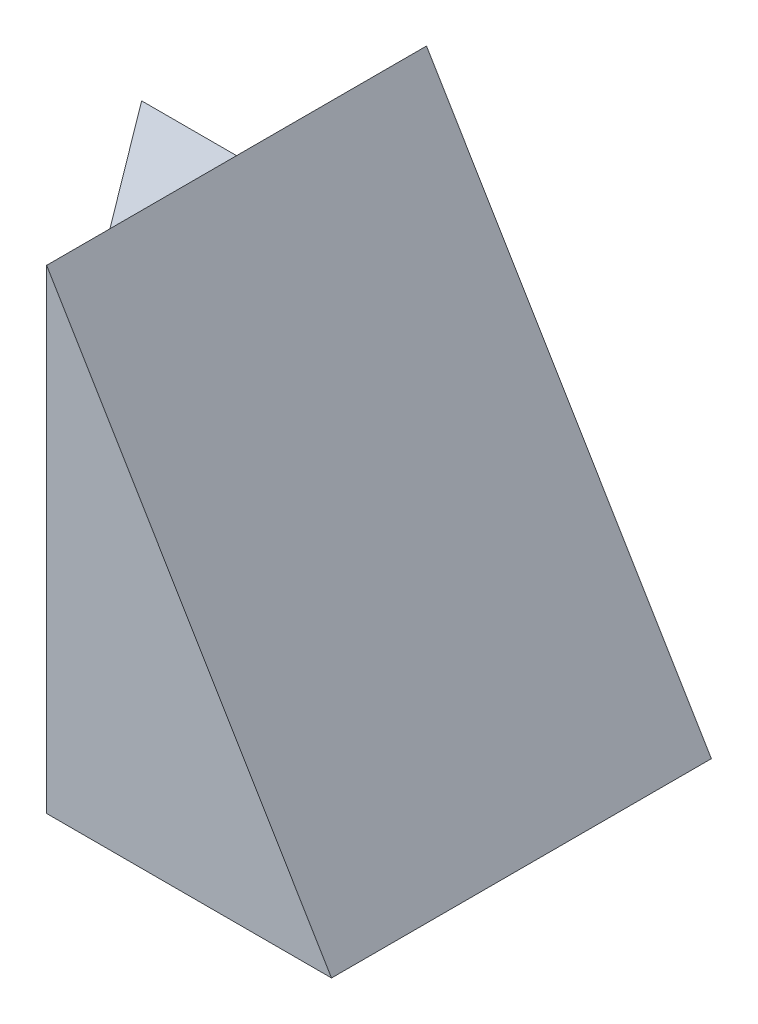
from build123d import *

# Parameters (mm, degrees)
BOSS_EXTRUDE1_DEPTH = 3
BOSS_EXTRUDE2_DEPTH = 4


with BuildPart() as part:
    # Sketch1 → Boss-Extrude1 (new body)
    with BuildSketch(Plane(origin=(0, 0, 0), x_dir=(1, 0, 0), z_dir=(0, 1, 0))):
        Polygon((0, 0), (-3, 4), (0, 4), align=None)
    extrude(amount=BOSS_EXTRUDE1_DEPTH)

    # Sketch2 → Boss-Extrude2 (add)
    with BuildSketch(Plane(origin=(0, 0, -4), x_dir=(-1, 0, 0), z_dir=(0, 0, -1))):
        Polygon((0, 5), (-3, 0), (0, 0), (0, 3), align=None)
    extrude(amount=-BOSS_EXTRUDE2_DEPTH)


solid = part.part
